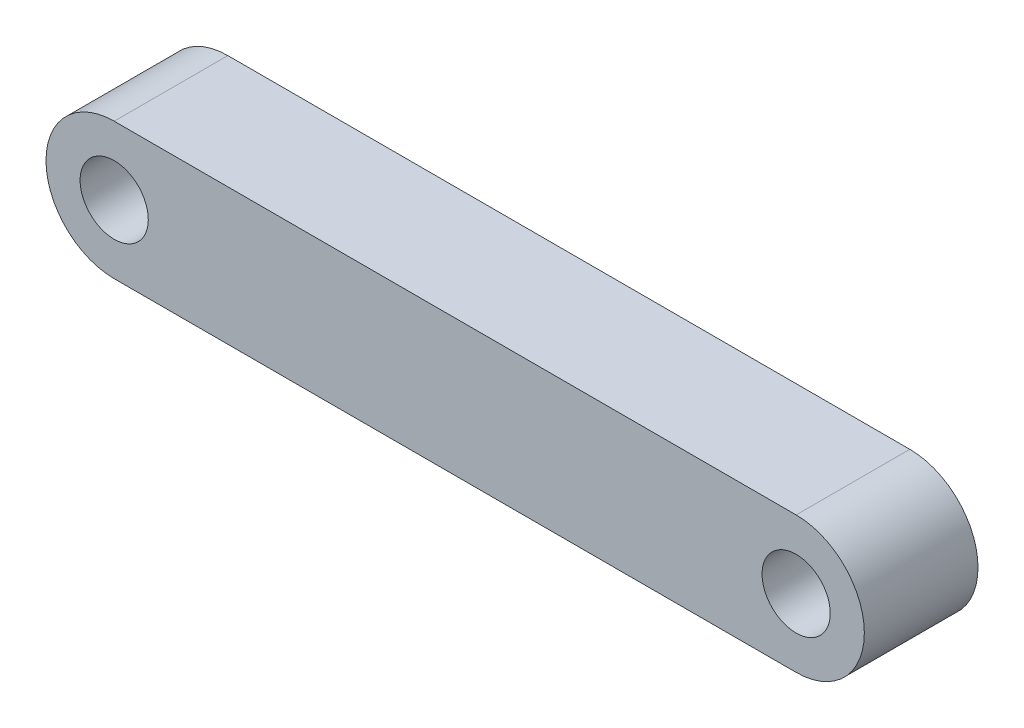
from build123d import *

# Parameters (mm, degrees)
SKETCH1_R           = 1.5
BOSS_EXTRUDE1_DEPTH = 5


with BuildPart() as part:
    # Sketch1 → Boss-Extrude1 (new body)
    with BuildSketch(Plane.XY):
        with BuildLine():
            Line((0, 3), (30, 3))
            ThreePointArc((30, 3), (33, 0), (30, -3))
            Line((30, -3), (0, -3))
            ThreePointArc((0, -3), (-3, 0), (0, 3))
        make_face()
        Circle(SKETCH1_R, mode=Mode.SUBTRACT)
        with Locations((30, 0)):
            Circle(SKETCH1_R, mode=Mode.SUBTRACT)
    extrude(amount=BOSS_EXTRUDE1_DEPTH)


solid = part.part
